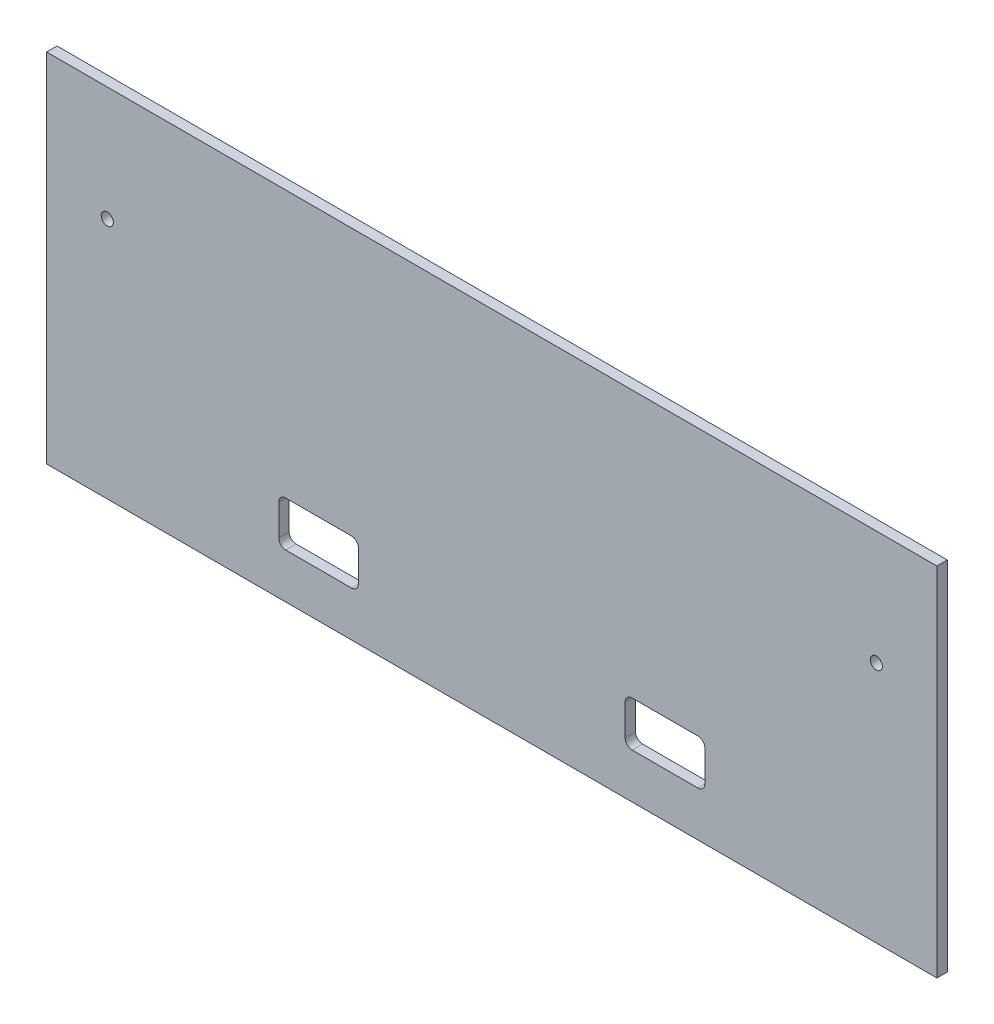
from build123d import *

# Parameters (mm, degrees)
ESQUISSE1_W             = 257
ESQUISSE1_H             = 103
ESQUISSE1_R             = 1.75
BOSS_EXTRU_1_DEPTH      = 3
ENL_V_MAT_EXTRU_1_REACH = 5
ESQUISSE2_W             = 23
ESQUISSE2_H             = 13
CONG_1_R                = 2


with BuildPart() as part:
    # Esquisse1 → Boss.-Extru.1 (new body)
    with BuildSketch(Plane.XY):
        Rectangle(ESQUISSE1_W, ESQUISSE1_H)
        with Locations((-111, 18.5)):
            Circle(ESQUISSE1_R, mode=Mode.SUBTRACT)
        with Locations((111, 18.5)):
            Circle(ESQUISSE1_R, mode=Mode.SUBTRACT)
    extrude(amount=BOSS_EXTRU_1_DEPTH)

    # Esquisse2 → Enlèv. mat.-Extru.1 (cut, up to next)
    with BuildSketch(Plane.XY.offset(3), mode=Mode.PRIVATE) as enl_v_mat_extru_1_sk1:
        with Locations((-50, -32)):
            Rectangle(ESQUISSE2_W, ESQUISSE2_H)
    enl_v_mat_extru_1_tool1 = extrude(enl_v_mat_extru_1_sk1.sketch, amount=-ENL_V_MAT_EXTRU_1_REACH, mode=Mode.PRIVATE) & part.part
    add(enl_v_mat_extru_1_tool1.solids().sort_by_distance((-50, -32, 3))[0], mode=Mode.SUBTRACT)
    # Esquisse2 → Enlèv. mat.-Extru.1 (cut, up to next)
    with BuildSketch(Plane.XY.offset(3), mode=Mode.PRIVATE) as enl_v_mat_extru_1_sk2:
        with Locations((50, -32)):
            Rectangle(ESQUISSE2_W, ESQUISSE2_H)
    enl_v_mat_extru_1_tool2 = extrude(enl_v_mat_extru_1_sk2.sketch, amount=-ENL_V_MAT_EXTRU_1_REACH, mode=Mode.PRIVATE) & part.part
    add(enl_v_mat_extru_1_tool2.solids().sort_by_distance((50, -32, 3))[0], mode=Mode.SUBTRACT)

    # Congé1
    cong_1_edges = [part.edges().sort_by_distance(p)[0] for p in [
        (-61.5, -38.5, 1.5),
        (-61.5, -25.5, 1.5),
        (-38.5, -25.5, 1.5),
        (-38.5, -38.5, 1.5),
        (38.5, -38.5, 1.5),
        (38.5, -25.5, 1.5),
        (61.5, -25.5, 1.5),
        (61.5, -38.5, 1.5),
    ]]
    fillet(cong_1_edges, radius=CONG_1_R)


solid = part.part
